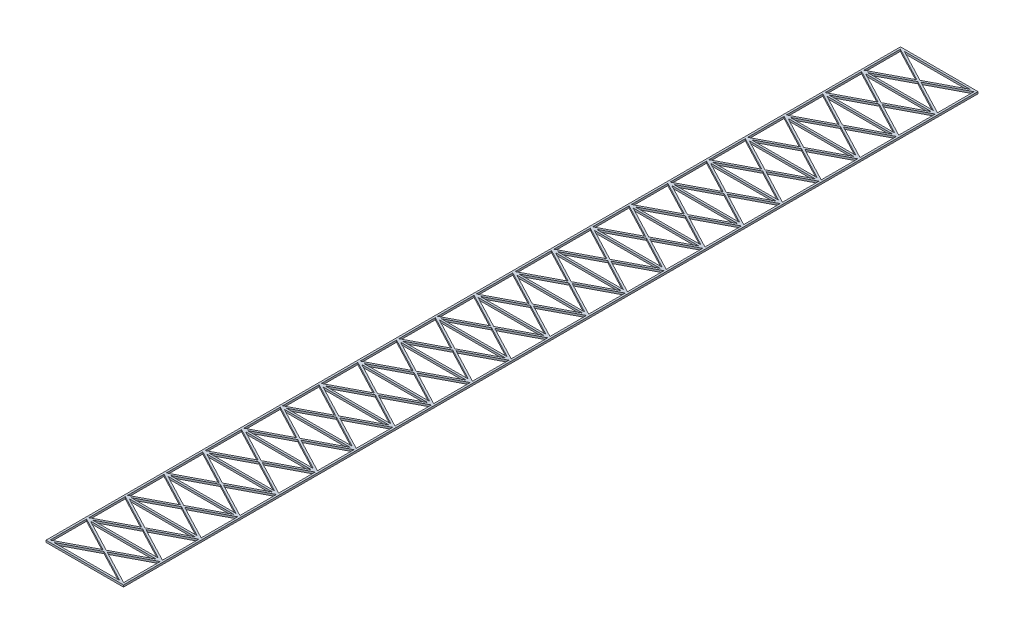
from build123d import *

# Parameters (mm, degrees)
SKETCH1_W           = 200
SKETCH1_H           = 105
SKETCH1_W_2         = 190
SKETCH1_H_2         = 95
BOSS_EXTRUDE1_DEPTH = 5
BOSS_EXTRUDE2_DEPTH = 5
BOSS_EXTRUDE3_DEPTH = 5
LPATTERN1_COUNT     = 22
LPATTERN1_PITCH     = 100


with BuildPart() as part:
    # Sketch1 → Boss-Extrude1 (new body)
    with BuildSketch(Plane(origin=(0, 0, 0), x_dir=(1, 0, 0), z_dir=(0, 1, 0))):
        with Locations((0, -52.5)):
            Rectangle(SKETCH1_W, SKETCH1_H)
        with Locations((0, -52.5)):
            Rectangle(SKETCH1_W_2, SKETCH1_H_2, mode=Mode.SUBTRACT)
    extrude(amount=BOSS_EXTRUDE1_DEPTH)

    # Sketch2 → Boss-Extrude2 (add)
    with BuildSketch(Plane.XZ):
        Polygon((100, 2.82358925), (-94.621734763, 105), (-100, 102.17641075), (94.621734763, 0), align=None)
    extrude(amount=-BOSS_EXTRUDE2_DEPTH)

    # Sketch3 → Boss-Extrude3 (add)
    with BuildSketch(Plane.XZ):
        Polygon((100, 102.17641075), (-94.621734763, 0), (-100, 2.82358925), (94.621734763, 105), align=None)
    extrude(amount=-BOSS_EXTRUDE3_DEPTH)

    # LPattern1: part ×22


with BuildPart() as part_1:
    add(part.part)
    with Locations(*[(0, 0, i * LPATTERN1_PITCH) for i in range(1, LPATTERN1_COUNT)]):
        add(part.part)


solid = part_1.part
